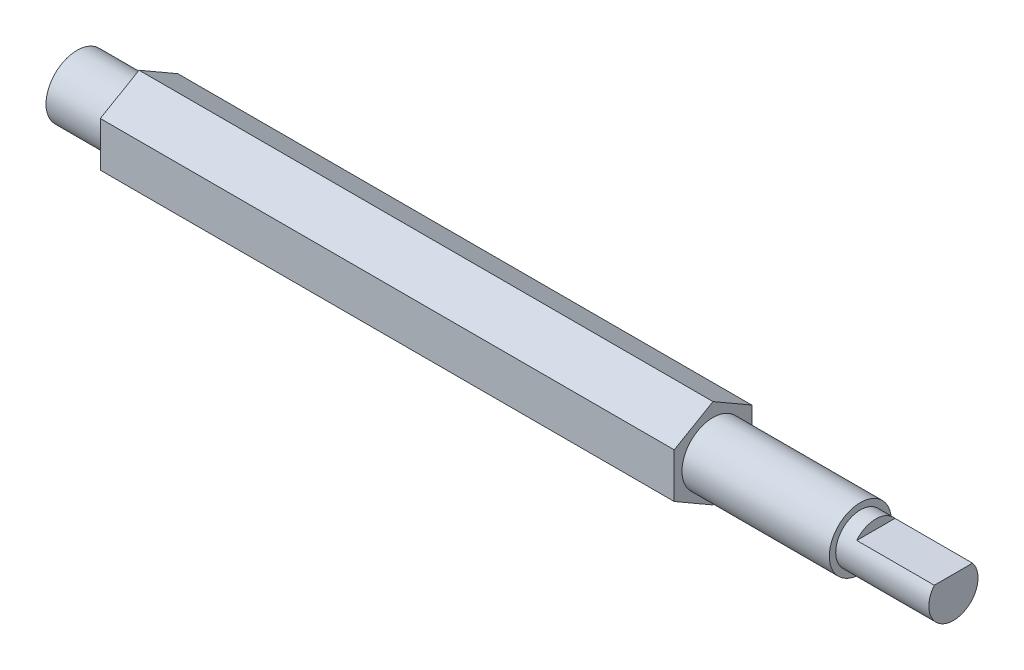
from build123d import *

# Parameters (mm, degrees)
BOSS_EXTRUDE1_DEPTH = 37
SKETCH4_W           = 8.655670696
SKETCH4_H           = 10.70324871
CUT_EXTRUDE1_DEPTH  = 2.886751346


with BuildPart() as part:
    # Sketch1 → Revolve1 (revolve)
    with BuildSketch(Plane.XY):
        Polygon((0, 2), (-4, 2), (-4, 0), (52.5, 0), (52.5, 1.5875), (46.5, 1.5875), (46.5, 2), (37, 2), (37, 2.5), (0, 2.5), align=None)
    revolve(axis=Axis((-6.185185185, 0, 0), (1, 0, 0)))

    # Sketch2 → Boss-Extrude1 (add)
    with BuildSketch(Plane(origin=(0, 0, 0), x_dir=(0, 0, -1), z_dir=(1, 0, 0))):
        Polygon((0, 2.886751346), (-2.5, 1.443375673), (-2.5, -1.443375673), (0, -2.886751346), (2.5, -1.443375673), (2.5, 1.443375673), align=None)
    extrude(amount=BOSS_EXTRUDE1_DEPTH)

    # Sketch4 → Cut-Extrude1 (cut, through all)
    with BuildSketch(Plane(origin=(0, 1, 0), x_dir=(1, 0, 0), z_dir=(0, 1, 0))):
        with Locations((51.827835348, -0.030836047)):
            Rectangle(SKETCH4_W, SKETCH4_H)
    extrude(amount=CUT_EXTRUDE1_DEPTH, mode=Mode.SUBTRACT)


solid = part.part
